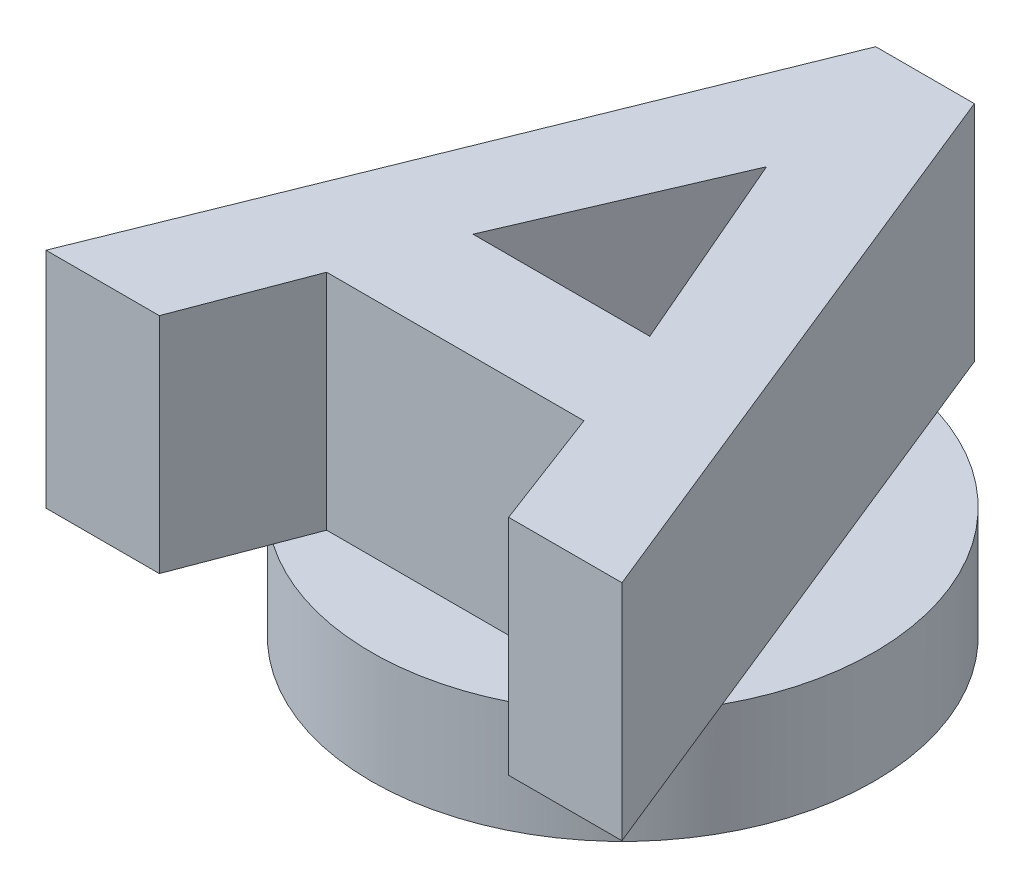
from build123d import *

# Parameters (mm, degrees)
SKETCH1_R           = 22.5
BOSS_EXTRUDE1_DEPTH = 10
BOSS_EXTRUDE2_DEPTH = 20
SKETCH3_R           = 16.5
CUT_EXTRUDE2_DEPTH  = 5


with BuildPart() as part:
    # Sketch1 → Boss-Extrude1 (new body)
    with BuildSketch(Plane(origin=(0, 0, 0), x_dir=(1, 0, 0), z_dir=(0, 1, 0))):
        with Locations(Location((0, 0, 0), (0, 0, 270))):
            Circle(SKETCH1_R)
    extrude(amount=BOSS_EXTRUDE1_DEPTH)

    # Sketch2 → Boss-Extrude2 (add)
    with BuildSketch(Plane(origin=(0, 10, 0), x_dir=(1, 0, 0), z_dir=(0, 1, 0))):
        Polygon((-4.383701715, 27.030528991), (4.446343023, 27.030528991), (25.81653533, -25.886137676), (15.672054161, -25.886137676), (11.559140165, -15.031436821), (-11.47529827, -15.031436821), (-15.598812559, -25.886137676), (-25.743293729, -25.886137676), align=None)
        Polygon((0.036620801, 12.836735588), (-7.871198377, -5.533573573), (7.955040272, -5.533573573), align=None, mode=Mode.SUBTRACT)
    extrude(amount=BOSS_EXTRUDE2_DEPTH)

    # Sketch3 → Cut-Extrude2 (cut)
    with BuildSketch(Plane.XZ):
        with BuildLine():
            ThreePointArc((-14.551420086, 2.778571429), (0, 11.5), (14.551420086, 2.778571429))
            Line((14.551420086, 2.778571429), (4.83856504, 20.948467447))
            ThreePointArc((4.83856504, 20.948467447), (0, 21.5), (-4.83856504, 20.948467447))
            Line((-4.83856504, 20.948467447), (-14.551420086, 2.778571429))
        make_face()
        with Locations((0, -5)):
            Circle(SKETCH3_R)
    extrude(amount=-CUT_EXTRUDE2_DEPTH, mode=Mode.SUBTRACT)


solid = part.part
